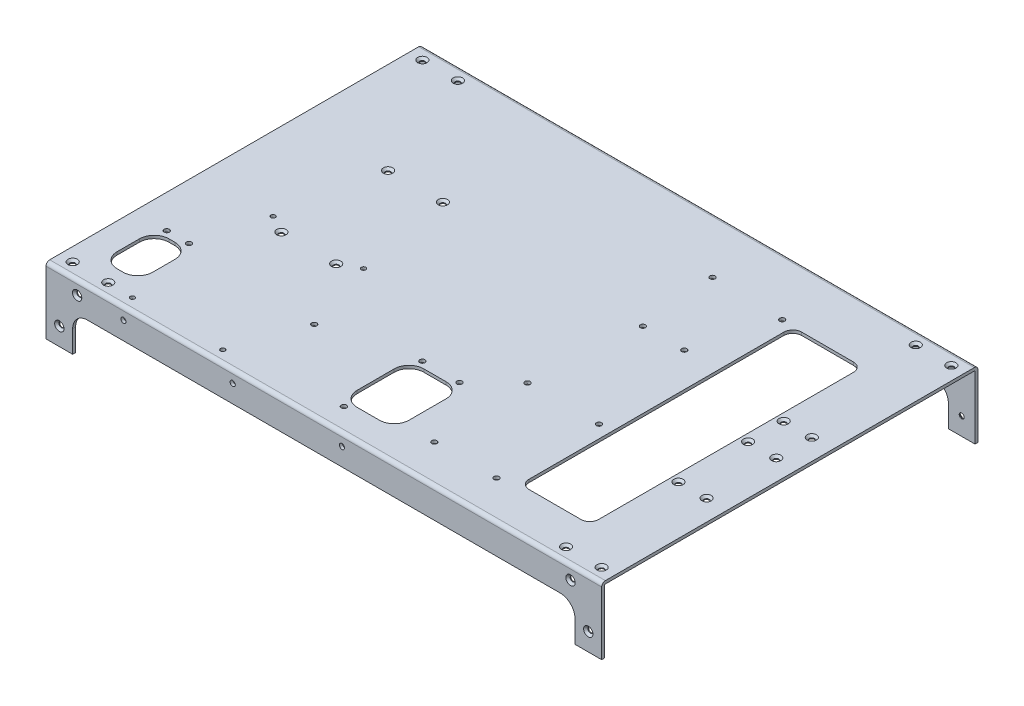
from build123d import *

# Parameters (mm, degrees)
BOSS_EXTRUDE1_DEPTH                             = 187.5
CUT_EXTRUDE1_DEPTH                              = 255
CUT_EXTRUDE4_DEPTH                              = 10
SKETCH6_R                                       = 1.5
CUT_EXTRUDE5_DEPTH                              = 255
SKETCH9_R                                       = 1.5
CUT_EXTRUDE8_DEPTH                              = 10
SKETCH19_R                                      = 1.5
CUT_EXTRUDE9_DEPTH                              = 10
SKETCH20_R                                      = 1.75
CUT_EXTRUDE10_DEPTH                             = 255
CSK_FOR_M3_FLAT_HEAD_MACHINE_SCREW1_D           = 3.4
CSK_FOR_M3_FLAT_HEAD_MACHINE_SCREW1_DEPTH       = 10
CSK_FOR_M3_FLAT_HEAD_MACHINE_SCREW1_CSINK_D     = 6.3
CSK_FOR_M3_FLAT_HEAD_MACHINE_SCREW1_CSINK_ANGLE = 90
CSK_FOR_M3_FLAT_HEAD_MACHINE_SCREW1_TIP         = 1.021463052
CSK_FOR_M3_FLAT_HEAD_MACHINE_SCREW2_D           = 3.4
CSK_FOR_M3_FLAT_HEAD_MACHINE_SCREW2_DEPTH       = 10
CSK_FOR_M3_FLAT_HEAD_MACHINE_SCREW2_CSINK_D     = 6.3
CSK_FOR_M3_FLAT_HEAD_MACHINE_SCREW2_CSINK_ANGLE = 90
CSK_FOR_M3_FLAT_HEAD_MACHINE_SCREW2_TIP         = 1.021463052
CSK_FOR_M3_FLAT_HEAD_MACHINE_SCREW3_D           = 3.4
CSK_FOR_M3_FLAT_HEAD_MACHINE_SCREW3_DEPTH       = 10
CSK_FOR_M3_FLAT_HEAD_MACHINE_SCREW3_CSINK_D     = 6.3
CSK_FOR_M3_FLAT_HEAD_MACHINE_SCREW3_CSINK_ANGLE = 90
CSK_FOR_M3_FLAT_HEAD_MACHINE_SCREW3_TIP         = 1.021463052
SKETCH28_R                                      = 1.75
CUT_EXTRUDE11_DEPTH                             = 10
SKETCH29_R                                      = 1.75
CUT_EXTRUDE12_DEPTH                             = 10
SKETCH30_R                                      = 1.75
CUT_EXTRUDE13_DEPTH                             = 3


with BuildPart() as part:
    # Sketch1 → Boss-Extrude1 (new body, symmetric)
    with BuildSketch(Plane(origin=(0, 0, 0), x_dir=(0, 0, -1), z_dir=(1, 0, 0))):
        with BuildLine():
            Line((125, -100.5), (127, -100.5))
            Line((127, -100.5), (127, -2.5))
            ThreePointArc((127, -2.5), (126.267766953, -0.732233047), (124.5, 0))
            Line((124.5, 0), (-124.5, 0))
            ThreePointArc((-124.5, 0), (-126.267766953, -0.732233047), (-127, -2.5))
            Line((-127, -2.5), (-127, -100.5))
            Line((-127, -100.5), (-125, -100.5))
            Line((-125, -100.5), (-125, -2.5))
            ThreePointArc((-125, -2.5), (-124.853553391, -2.146446609), (-124.5, -2))
            Line((-124.5, -2), (124.5, -2))
            ThreePointArc((124.5, -2), (124.853553391, -2.146446609), (125, -2.5))
            Line((125, -2.5), (125, -100.5))
        make_face()
    extrude(amount=BOSS_EXTRUDE1_DEPTH, both=True)

    # Sketch2 → Cut-Extrude1 (cut, through all)
    with BuildSketch(Plane.XY.offset(127)):
        with BuildLine():
            Line((187.5, -45), (187.5, -100.5))
            Line((187.5, -100.5), (-187.5, -100.5))
            Line((-187.5, -100.5), (-187.5, -45))
            Line((-187.5, -45), (-169.5, -45))
            Line((-169.5, -45), (-169.5, -30))
            ThreePointArc((-169.5, -30), (-166.571067812, -22.928932188), (-159.5, -20))
            Line((-159.5, -20), (159.5, -20))
            ThreePointArc((159.5, -20), (166.571067812, -22.928932188), (169.5, -30))
            Line((169.5, -30), (169.5, -45))
            Line((169.5, -45), (187.5, -45))
        make_face()
    extrude(amount=-CUT_EXTRUDE1_DEPTH, mode=Mode.SUBTRACT)

    # Sketch5 → Cut-Extrude4 (cut)
    with BuildSketch(Plane.XZ.offset(2)):
        with BuildLine():
            Line((108.5, 97), (143.5, 97))
            ThreePointArc((143.5, 97), (147.742640687, 95.242640687), (149.5, 91))
            Line((149.5, 91), (149.5, -81))
            ThreePointArc((149.5, -81), (147.742640687, -85.242640687), (143.5, -87))
            Line((143.5, -87), (108.5, -87))
            ThreePointArc((108.5, -87), (104.257359313, -85.242640687), (102.5, -81))
            Line((102.5, -81), (102.5, 91))
            ThreePointArc((102.5, 91), (104.257359313, 95.242640687), (108.5, 97))
        make_face()
    extrude(amount=-CUT_EXTRUDE4_DEPTH, mode=Mode.SUBTRACT)

    # Sketch6 → Cut-Extrude5 (cut, through all)
    with BuildSketch(Plane(origin=(0, 0, -127), x_dir=(-1, 0, 0), z_dir=(0, 0, -1))):
        with Locations((-178.5, -33)):
            Circle(SKETCH6_R)
        with Locations((-166.5, -9)):
            Circle(SKETCH6_R)
        with Locations((166.5, -9)):
            Circle(SKETCH6_R)
        with Locations((178.5, -33)):
            Circle(SKETCH6_R)
    extrude(amount=-CUT_EXTRUDE5_DEPTH, mode=Mode.SUBTRACT)

    # Sketch9 → Cut-Extrude8 (cut)
    with BuildSketch(Plane(origin=(0, 0, 0), x_dir=(1, 0, 0), z_dir=(0, 1, 0))):
        with Locations(Location((-178.5, 118, 0), (0, 0, 270))):  # turned: the seam where the file's is
            Circle(SKETCH9_R)
        with Locations(Location((-154.5, 118, 0), (0, 0, 270))):  # turned: the seam where the file's is
            Circle(SKETCH9_R)
        with Locations(Location((154.5, 118, 0), (0, 0, 270))):  # turned: the seam where the file's is
            Circle(SKETCH9_R)
        with Locations(Location((178.5, 118, 0), (0, 0, 270))):  # turned: the seam where the file's is
            Circle(SKETCH9_R)
        with Locations(Location((178.5, -118, 0), (0, 0, 270))):  # turned: the seam where the file's is
            Circle(SKETCH9_R)
        with Locations(Location((154.5, -118, 0), (0, 0, 270))):  # turned: the seam where the file's is
            Circle(SKETCH9_R)
        with Locations(Location((-154.5, -118, 0), (0, 0, 270))):  # turned: the seam where the file's is
            Circle(SKETCH9_R)
        with Locations(Location((-178.5, -118, 0), (0, 0, 270))):  # turned: the seam where the file's is
            Circle(SKETCH9_R)
        with Locations(Location((-125.5, 41.85, 0), (0, 0, 270))):  # turned: the seam where the file's is
            Circle(SKETCH9_R)
        with Locations(Location((-88.5, 41.85, 0), (0, 0, 270))):  # turned: the seam where the file's is
            Circle(SKETCH9_R)
        with Locations(Location((-125.5, -30.15, 0), (0, 0, 270))):  # turned: the seam where the file's is
            Circle(SKETCH9_R)
        with Locations(Location((-88.5, -30.15, 0), (0, 0, 270))):  # turned: the seam where the file's is
            Circle(SKETCH9_R)
        with Locations(Location((154.5, 28.85, 0), (0, 0, 270))):  # turned: the seam where the file's is
            Circle(SKETCH9_R)
        with Locations(Location((173.5, 4.85, 0), (0, 0, 270))):  # turned: the seam where the file's is
            Circle(SKETCH9_R)
        with Locations(Location((154.5, 4.85, 0), (0, 0, 270))):  # turned: the seam where the file's is
            Circle(SKETCH9_R)
        with Locations(Location((173.5, 28.85, 0), (0, 0, 270))):  # turned: the seam where the file's is
            Circle(SKETCH9_R)
        with Locations(Location((154.5, -42.15, 0), (0, 0, 270))):  # turned: the seam where the file's is
            Circle(SKETCH9_R)
        with Locations(Location((173.5, -42.15, 0), (0, 0, 270))):  # turned: the seam where the file's is
            Circle(SKETCH9_R)
    extrude(amount=-CUT_EXTRUDE8_DEPTH, mode=Mode.SUBTRACT)

    # Sketch19 → Cut-Extrude9 (cut)
    with BuildSketch(Plane(origin=(0, 0, 0), x_dir=(1, 0, 0), z_dir=(0, 1, 0))):
        with Locations(Location((-137.5, -23.7, 0), (0, 0, 270))):  # turned: the seam where the file's is
            Circle(SKETCH19_R)
        with Locations(Location((-76.5, -23.7, 0), (0, 0, 270))):  # turned: the seam where the file's is
            Circle(SKETCH19_R)
        with Locations(Location((-76.5, -118.7, 0), (0, 0, 270))):  # turned: the seam where the file's is
            Circle(SKETCH19_R)
        with Locations(Location((-137.5, -118.7, 0), (0, 0, 270))):  # turned: the seam where the file's is
            Circle(SKETCH19_R)
    extrude(amount=-CUT_EXTRUDE9_DEPTH, mode=Mode.SUBTRACT)

    # Sketch20 → Cut-Extrude10 (cut, through all)
    with BuildSketch(Plane(origin=(0, 0, -127), x_dir=(-1, 0, 0), z_dir=(0, 0, -1))):
        with Locations((-12.25, -8)):
            Circle(SKETCH20_R)
        with Locations((61.5, -8)):
            Circle(SKETCH20_R)
        with Locations((135.25, -8)):
            Circle(SKETCH20_R)
    extrude(amount=-CUT_EXTRUDE10_DEPTH, mode=Mode.SUBTRACT)

    # CSK for M3 Flat Head Machine Screw1
    with Locations(Plane.XY.offset(127)):
        with Locations((-166.5, -9), (166.5, -9), (178.5, -33), (-178.5, -33)):
            CounterSinkHole(CSK_FOR_M3_FLAT_HEAD_MACHINE_SCREW1_D / 2, CSK_FOR_M3_FLAT_HEAD_MACHINE_SCREW1_CSINK_D / 2, depth=CSK_FOR_M3_FLAT_HEAD_MACHINE_SCREW1_DEPTH, counter_sink_angle=CSK_FOR_M3_FLAT_HEAD_MACHINE_SCREW1_CSINK_ANGLE)
            with Locations((0, 0, -(CSK_FOR_M3_FLAT_HEAD_MACHINE_SCREW1_DEPTH + CSK_FOR_M3_FLAT_HEAD_MACHINE_SCREW1_TIP / 2))):  # 118° drill point
                Cone(0, CSK_FOR_M3_FLAT_HEAD_MACHINE_SCREW1_D / 2, CSK_FOR_M3_FLAT_HEAD_MACHINE_SCREW1_TIP, mode=Mode.SUBTRACT)

    # CSK for M3 Flat Head Machine Screw2
    with Locations(Plane(origin=(0, 0, -127), x_dir=(-1, 0, 0), z_dir=(0, 0, -1))):
        with Locations((-166.5, -9), (178.5, -33), (166.5, -9), (-178.5, -33)):
            CounterSinkHole(CSK_FOR_M3_FLAT_HEAD_MACHINE_SCREW2_D / 2, CSK_FOR_M3_FLAT_HEAD_MACHINE_SCREW2_CSINK_D / 2, depth=CSK_FOR_M3_FLAT_HEAD_MACHINE_SCREW2_DEPTH, counter_sink_angle=CSK_FOR_M3_FLAT_HEAD_MACHINE_SCREW2_CSINK_ANGLE)
            with Locations((0, 0, -(CSK_FOR_M3_FLAT_HEAD_MACHINE_SCREW2_DEPTH + CSK_FOR_M3_FLAT_HEAD_MACHINE_SCREW2_TIP / 2))):  # 118° drill point
                Cone(0, CSK_FOR_M3_FLAT_HEAD_MACHINE_SCREW2_D / 2, CSK_FOR_M3_FLAT_HEAD_MACHINE_SCREW2_TIP, mode=Mode.SUBTRACT)

    # CSK for M3 Flat Head Machine Screw3
    with Locations(Plane(origin=(0, 0, 0), x_dir=(-1, 0, 0), z_dir=(0, 1, 0))):
        with Locations((88.5, -41.85), (178.5, -118), (154.5, -118), (125.5, -41.85), (125.5, 30.15), (88.5, 30.15), (178.5, 118), (154.5, 118), (-154.5, 118), (-178.5, 118), (-154.5, 42.15), (-173.5, 42.15), (-173.5, -4.85), (-154.5, -4.85), (-173.5, -28.85), (-154.5, -28.85), (-178.5, -118), (-154.5, -118)):
            CounterSinkHole(CSK_FOR_M3_FLAT_HEAD_MACHINE_SCREW3_D / 2, CSK_FOR_M3_FLAT_HEAD_MACHINE_SCREW3_CSINK_D / 2, depth=CSK_FOR_M3_FLAT_HEAD_MACHINE_SCREW3_DEPTH, counter_sink_angle=CSK_FOR_M3_FLAT_HEAD_MACHINE_SCREW3_CSINK_ANGLE)
            with Locations((0, 0, -(CSK_FOR_M3_FLAT_HEAD_MACHINE_SCREW3_DEPTH + CSK_FOR_M3_FLAT_HEAD_MACHINE_SCREW3_TIP / 2))):  # 118° drill point
                Cone(0, CSK_FOR_M3_FLAT_HEAD_MACHINE_SCREW3_D / 2, CSK_FOR_M3_FLAT_HEAD_MACHINE_SCREW3_TIP, mode=Mode.SUBTRACT)

    # Sketch28 → Cut-Extrude11 (cut)
    with BuildSketch(Plane(origin=(0, 0, 0), x_dir=(-1, 0, 0), z_dir=(0, 1, 0))):
        with Locations(Location((2.5, 111, 0), (0, 0, 90))):  # turned: the seam where the file's is
            Circle(SKETCH28_R)
        with Locations(Location((2.5, 58, 0), (0, 0, 90))):  # turned: the seam where the file's is
            Circle(SKETCH28_R)
        with Locations(Location((-22.5, 58, 0), (0, 0, 90))):  # turned: the seam where the file's is
            Circle(SKETCH28_R)
        with Locations(Location((150, 68, 0), (0, 0, 90))):  # turned: the seam where the file's is
            Circle(SKETCH28_R)
        with Locations(Location((165, 68, 0), (0, 0, 90))):  # turned: the seam where the file's is
            Circle(SKETCH28_R)
        with BuildLine():
            Line((-2.5, 62), (-17.5, 62))
            ThreePointArc((-17.5, 62), (-24.571067812, 64.928932188), (-27.5, 72))
            Line((-27.5, 72), (-27.5, 97))
            ThreePointArc((-27.5, 97), (-24.571067812, 104.071067812), (-17.5, 107))
            Line((-17.5, 107), (-2.5, 107))
            ThreePointArc((-2.5, 107), (4.571067812, 104.071067812), (7.5, 97))
            Line((7.5, 97), (7.5, 72))
            ThreePointArc((7.5, 72), (4.571067812, 64.928932188), (-2.5, 62))
        make_face()
        with BuildLine():
            Line((155.5, 107), (159.5, 107))
            ThreePointArc((159.5, 107), (166.571067812, 104.071067812), (169.5, 97))
            Line((169.5, 97), (169.5, 82))
            ThreePointArc((169.5, 82), (166.571067812, 74.928932188), (159.5, 72))
            Line((159.5, 72), (155.5, 72))
            ThreePointArc((155.5, 72), (148.428932188, 74.928932188), (145.5, 82))
            Line((145.5, 82), (145.5, 97))
            ThreePointArc((145.5, 97), (148.428932188, 104.071067812), (155.5, 107))
        make_face()
    extrude(amount=-CUT_EXTRUDE11_DEPTH, mode=Mode.SUBTRACT)

    # Sketch29 → Cut-Extrude12 (cut)
    with BuildSketch(Plane.XZ.offset(2)):
        with Locations(Location((48.87606739, 101.261331894, 0), (0, 0, 270))):  # turned: the seam where the file's is
            Circle(SKETCH29_R)
        with Locations(Location((90.786066711, 101.253791257, 0), (0, 0, 270))):  # turned: the seam where the file's is
            Circle(SKETCH29_R)
        with Locations(Location((45.689185225, 35.221904223, 0), (0, 0, 270))):  # turned: the seam where the file's is
            Circle(SKETCH29_R)
        with Locations(Location((93.949184444, 35.213221065, 0), (0, 0, 270))):  # turned: the seam where the file's is
            Circle(SKETCH29_R)
        with Locations(Location((51.527, -36.839, 0), (0, 0, 270))):  # turned: the seam where the file's is
            Circle(SKETCH29_R)
        with Locations(Location((79.467, -36.839, 0), (0, 0, 270))):  # turned: the seam where the file's is
            Circle(SKETCH29_R)
        with Locations(Location((46.447, -88.91, 0), (0, 0, 270))):  # turned: the seam where the file's is
            Circle(SKETCH29_R)
        with Locations(Location((94.707, -87.639, 0), (0, 0, 270))):  # turned: the seam where the file's is
            Circle(SKETCH29_R)
    extrude(amount=-CUT_EXTRUDE12_DEPTH, mode=Mode.SUBTRACT)

    # Sketch30 → Cut-Extrude13 (cut, through all)
    with BuildSketch(Plane.XZ.offset(2)):
        with Locations(Location((-60.5, 73, 0), (0, 0, 270))):  # turned: the seam where the file's is
            Circle(SKETCH30_R)
    extrude(amount=-CUT_EXTRUDE13_DEPTH, mode=Mode.SUBTRACT)


solid = part.part
